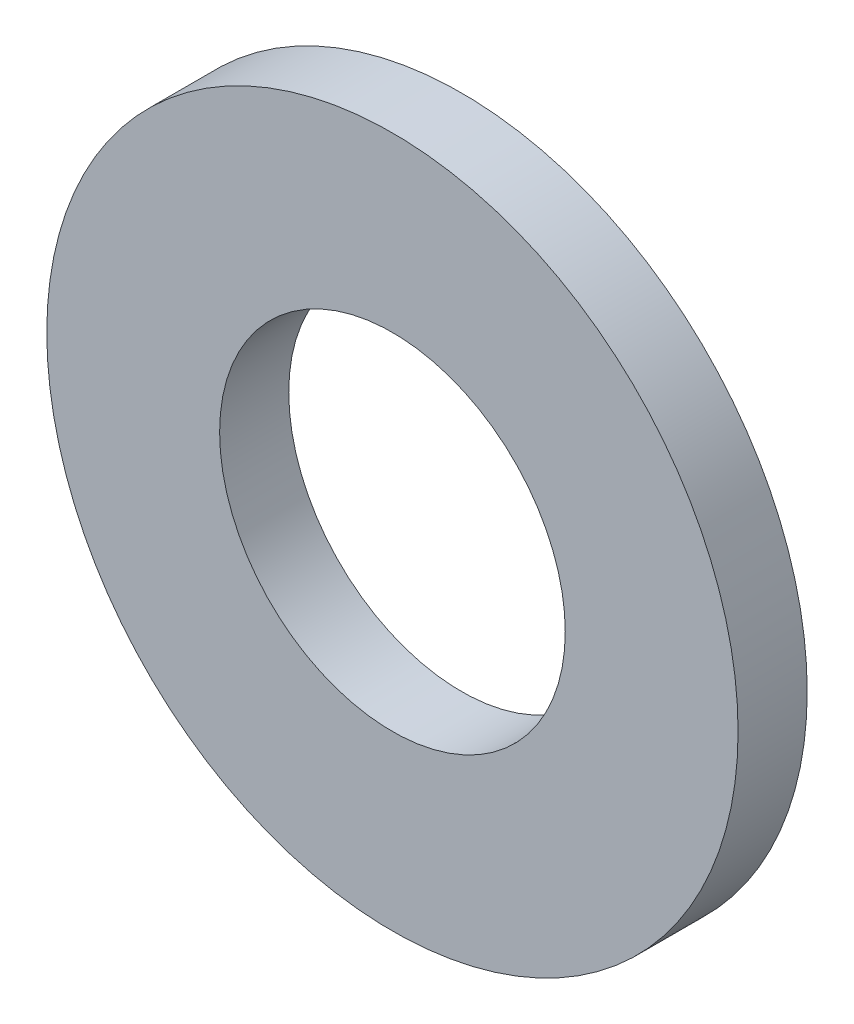
from build123d import *

# Parameters (mm, degrees)
SKETCH1_R           = 10
BOSS_EXTRUDE1_DEPTH = 2
SKETCH2_R           = 5
CUT_EXTRUDE1_DEPTH  = 4


with BuildPart() as part:
    # Sketch1 → Boss-Extrude1 (new body)
    with BuildSketch(Plane.XY):
        Circle(SKETCH1_R)
    extrude(amount=BOSS_EXTRUDE1_DEPTH)

    # Sketch2 → Cut-Extrude1 (cut)
    with BuildSketch(Plane.XY.offset(2)):
        Circle(SKETCH2_R)
    extrude(amount=-CUT_EXTRUDE1_DEPTH, mode=Mode.SUBTRACT)


solid = part.part
